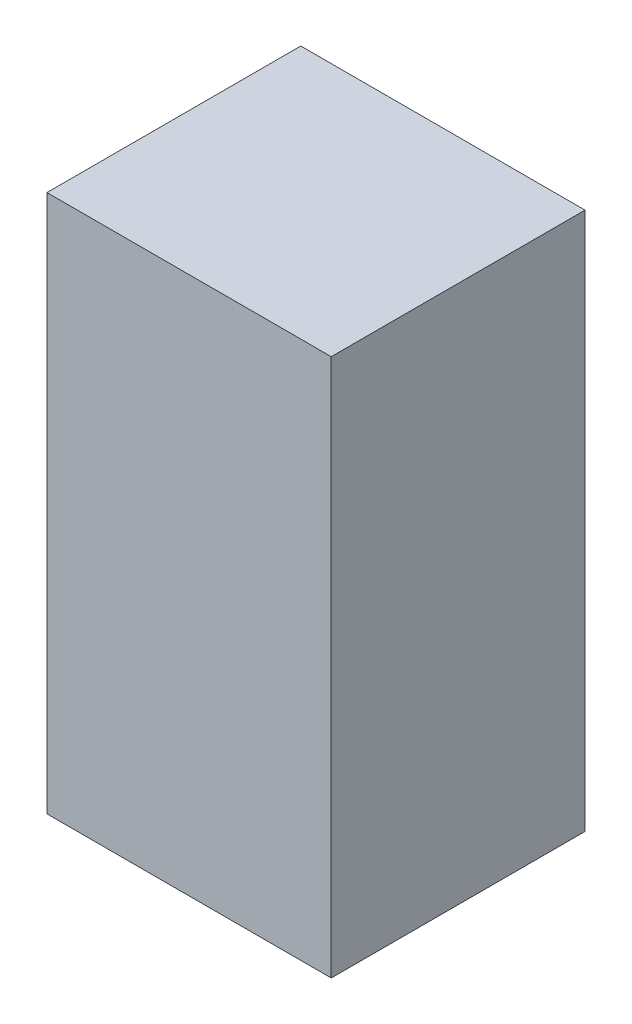
from build123d import *

# Parameters (mm, degrees)
SKETCH1_W           = 7.112
SKETCH1_H           = 13.462
BOSS_EXTRUDE1_DEPTH = 6.35


with BuildPart() as part:
    # Sketch1 → Boss-Extrude1 (new body)
    with BuildSketch(Plane.XY):
        with Locations((3.556, 6.731)):
            Rectangle(SKETCH1_W, SKETCH1_H)
    extrude(amount=BOSS_EXTRUDE1_DEPTH)


solid = part.part
